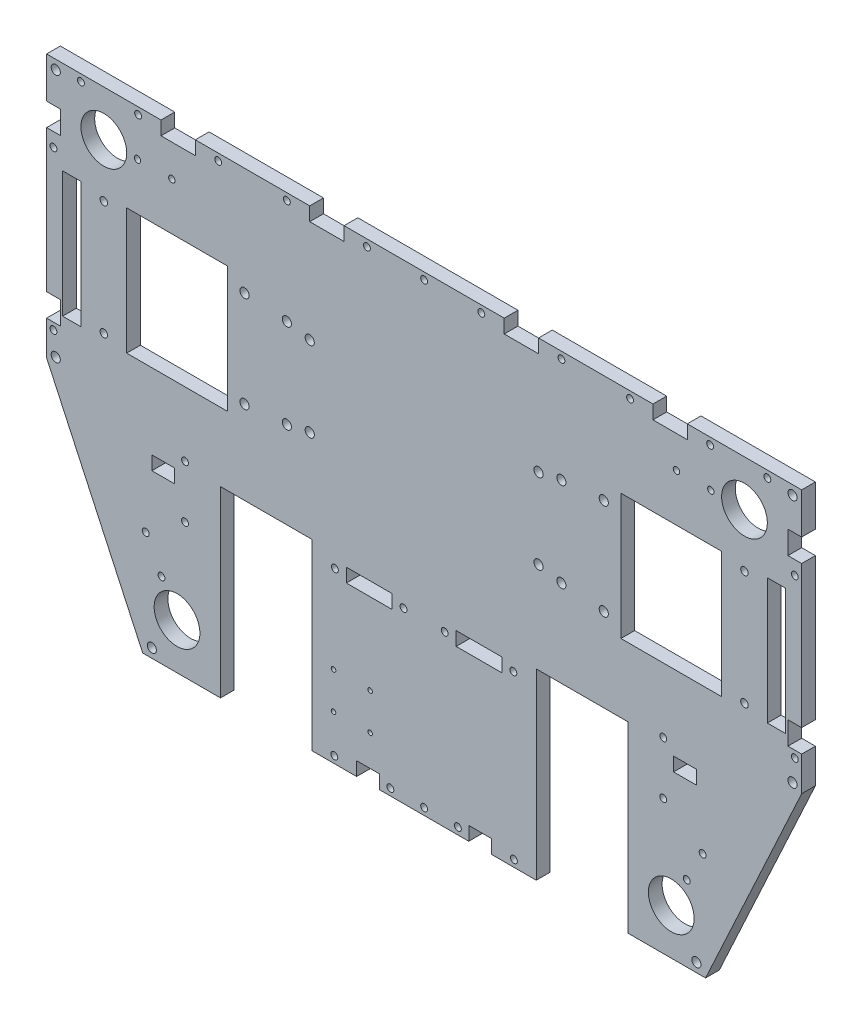
from build123d import *

# Parameters (mm, degrees)
ESQUISSE1_R             = 1
BOSS_EXTRU_1_DEPTH      = 6
ESQUISSE2_R             = 10
ESQUISSE2_R_2           = 2
ESQUISSE2_R_3           = 1.4
ESQUISSE2_R_4           = 1.5
ESQUISSE2_W             = 8
ESQUISSE2_H             = 55
ESQUISSE2_W_2           = 44
ESQUISSE2_W_3           = 40
ESQUISSE2_H_2           = 80
ENL_V_MAT_EXTRU_1_DEPTH = 6
ESQUISSE3_W             = 6
ESQUISSE3_H             = 10
ESQUISSE3_W_2           = 10
ESQUISSE3_H_2           = 6
ESQUISSE3_W_3           = 15
ENL_V_MAT_EXTRU_2_DEPTH = 6
ESQUISSE4_R             = 1.5
ENL_V_MAT_EXTRU_3_DEPTH = 6
ESQUISSE5_W             = 10
ESQUISSE5_H             = 6
ESQUISSE5_W_2           = 20
ENL_V_MAT_EXTRU_4_DEPTH = 6
ESQUISSE6_R             = 1.65
ESQUISSE6_R_2           = 1.5
ESQUISSE6_R_3           = 2
ENL_V_MAT_EXTRU_5_DEPTH = 6


with BuildPart() as part:
    # Esquisse1 → Boss.-Extru.1 (new body)
    with BuildSketch(Plane.XY):
        Polygon((-165, 96.73), (165, 96.73), (165, -18.27), (123, -109.022410436), (-123, -109.022410436), (-165, -18.27), align=None)
        with Locations((-23.6, -89.522410436)):
            Circle(ESQUISSE1_R, mode=Mode.SUBTRACT)
        with Locations((-23.6, -73.522410436)):
            Circle(ESQUISSE1_R, mode=Mode.SUBTRACT)
        with Locations((-39.6, -89.522410436)):
            Circle(ESQUISSE1_R, mode=Mode.SUBTRACT)
        with Locations((-39.6, -73.522410436)):
            Circle(ESQUISSE1_R, mode=Mode.SUBTRACT)
    extrude(amount=BOSS_EXTRU_1_DEPTH)

    # Esquisse2 → Enlèv. mat.-Extru.1 (cut)
    with BuildSketch(Plane.XY.offset(6)):
        with Locations((140, 76.73)):
            Circle(ESQUISSE2_R)
        with Locations((108, -89.022410436)):
            Circle(ESQUISSE2_R)
        with Locations((-140, 76.73)):
            Circle(ESQUISSE2_R)
        with Locations((-108, -89.022410436)):
            Circle(ESQUISSE2_R)
        with Locations((161, -16.022410436)):
            Circle(ESQUISSE2_R_2)
        with Locations((119, -105.022410436)):
            Circle(ESQUISSE2_R_2)
        with Locations((161, 92.73)):
            Circle(ESQUISSE2_R_2)
        with Locations((-161, 92.73)):
            Circle(ESQUISSE2_R_2)
        with Locations((-161, -16.022410436)):
            Circle(ESQUISSE2_R_2)
        with Locations((-119, -105.022410436)):
            Circle(ESQUISSE2_R_2)
        with Locations((125.27, 76.73)):
            Circle(ESQUISSE2_R_3)
        with Locations((110.27, 76.73)):
            Circle(ESQUISSE2_R_3)
        with Locations((114.7893454, -75.950391119)):
            Circle(ESQUISSE2_R_4)
        with Locations((121.703139086, -62.638762485)):
            Circle(ESQUISSE2_R_4)
        with Locations((-110.27, 76.73)):
            Circle(ESQUISSE2_R_3)
        with Locations((-125.27, 76.73)):
            Circle(ESQUISSE2_R_3)
        with Locations((-121.703139086, -62.638762485)):
            Circle(ESQUISSE2_R_4)
        with Locations((-114.7893454, -75.950391119)):
            Circle(ESQUISSE2_R_4)
        with Locations((-154, 28.477589564)):
            Rectangle(ESQUISSE2_W, ESQUISSE2_H)
        with Locations((-108, 28.477589564)):
            Rectangle(ESQUISSE2_W_2, ESQUISSE2_H)
        with Locations((108, 28.477589564)):
            Rectangle(ESQUISSE2_W_2, ESQUISSE2_H)
        with Locations((154, 28.477589564)):
            Rectangle(ESQUISSE2_W, ESQUISSE2_H)
        with Locations((69, -69.022410436)):
            Rectangle(ESQUISSE2_W_3, ESQUISSE2_H_2)
        with Locations((-69, -69.022410436)):
            Rectangle(ESQUISSE2_W_3, ESQUISSE2_H_2)
    extrude(amount=-ENL_V_MAT_EXTRU_1_DEPTH, mode=Mode.SUBTRACT)

    # Esquisse3 → Enlèv. mat.-Extru.2 (cut)
    with BuildSketch(Plane(origin=(0, 0, 0), x_dir=(-1, 0, 0), z_dir=(0, 0, -1))):
        with Locations((162, 1.73)):
            Rectangle(ESQUISSE3_W, ESQUISSE3_H)
        with Locations((162, 73.852589564)):
            Rectangle(ESQUISSE3_W, ESQUISSE3_H)
        with Locations((24.5, -106.022410436)):
            Rectangle(ESQUISSE3_W_2, ESQUISSE3_H_2)
        with Locations((-24.5, -106.022410436)):
            Rectangle(ESQUISSE3_W_2, ESQUISSE3_H_2)
        with Locations((-162, 73.852589564)):
            Rectangle(ESQUISSE3_W, ESQUISSE3_H)
        with Locations((-162, 1.73)):
            Rectangle(ESQUISSE3_W, ESQUISSE3_H)
        with Locations((107.5, 93.73)):
            Rectangle(ESQUISSE3_W_3, ESQUISSE3_H_2)
        with Locations((-42.5, 93.73)):
            Rectangle(ESQUISSE3_W_3, ESQUISSE3_H_2)
        with Locations((42.5, 93.73)):
            Rectangle(ESQUISSE3_W_3, ESQUISSE3_H_2)
        with Locations((-107.5, 93.73)):
            Rectangle(ESQUISSE3_W_3, ESQUISSE3_H_2)
    extrude(amount=-ENL_V_MAT_EXTRU_2_DEPTH, mode=Mode.SUBTRACT)

    # Esquisse4 → Enlèv. mat.-Extru.3 (cut)
    with BuildSketch(Plane(origin=(0, 0, 0), x_dir=(-1, 0, 0), z_dir=(0, 0, -1))):
        with Locations((162, -6.27)):
            Circle(ESQUISSE4_R)
        with Locations((0, -106.022410436)):
            Circle(ESQUISSE4_R)
        with Locations((162, 62.852589564)):
            Circle(ESQUISSE4_R)
        with Locations((0, 93.73)):
            Circle(ESQUISSE4_R)
        with Locations((-39.25, -106.022410436)):
            Circle(ESQUISSE4_R)
        with Locations((-14.75, -106.022410436)):
            Circle(ESQUISSE4_R)
        with Locations((14.75, -106.022410436)):
            Circle(ESQUISSE4_R)
        with Locations((39.25, -106.022410436)):
            Circle(ESQUISSE4_R)
        with Locations((150, 93.73)):
            Circle(ESQUISSE4_R)
        with Locations((125, 93.73)):
            Circle(ESQUISSE4_R)
        with Locations((90, 93.73)):
            Circle(ESQUISSE4_R)
        with Locations((-25, 93.73)):
            Circle(ESQUISSE4_R)
        with Locations((60, 93.73)):
            Circle(ESQUISSE4_R)
        with Locations((25, 93.73)):
            Circle(ESQUISSE4_R)
        with Locations((-60, 93.73)):
            Circle(ESQUISSE4_R)
        with Locations((-90, 93.73)):
            Circle(ESQUISSE4_R)
        with Locations((-125, 93.73)):
            Circle(ESQUISSE4_R)
        with Locations((-150, 93.73)):
            Circle(ESQUISSE4_R)
        with Locations((-162, 62.852589564)):
            Circle(ESQUISSE4_R)
        with Locations((-162, -6.27)):
            Circle(ESQUISSE4_R)
    extrude(amount=-ENL_V_MAT_EXTRU_3_DEPTH, mode=Mode.SUBTRACT)

    # Esquisse5 → Enlèv. mat.-Extru.4 (cut)
    with BuildSketch(Plane(origin=(0, 0, 0), x_dir=(-1, 0, 0), z_dir=(0, 0, -1))):
        with Locations((114, -35.022410436)):
            Rectangle(ESQUISSE5_W, ESQUISSE5_H)
        with Locations((24, -35.022410436)):
            Rectangle(ESQUISSE5_W_2, ESQUISSE5_H)
        with Locations((-24, -35.022410436)):
            Rectangle(ESQUISSE5_W_2, ESQUISSE5_H)
        with Locations((-114, -35.022410436)):
            Rectangle(ESQUISSE5_W, ESQUISSE5_H)
    extrude(amount=-ENL_V_MAT_EXTRU_4_DEPTH, mode=Mode.SUBTRACT)

    # Esquisse6 → Enlèv. mat.-Extru.5 (cut)
    with BuildSketch(Plane(origin=(0, 0, 0), x_dir=(-1, 0, 0), z_dir=(0, 0, -1))):
        with Locations((-140, 3.477589564)):
            Circle(ESQUISSE6_R)
        with Locations((-140, 53.477589564)):
            Circle(ESQUISSE6_R)
        with Locations((140, 53.477589564)):
            Circle(ESQUISSE6_R)
        with Locations((140, 3.477589564)):
            Circle(ESQUISSE6_R)
        with Locations((-39, -35.022410436)):
            Circle(ESQUISSE6_R_2)
        with Locations((9, -35.022410436)):
            Circle(ESQUISSE6_R_2)
        with Locations((39, -35.022410436)):
            Circle(ESQUISSE6_R_2)
        with Locations((-9, -35.022410436)):
            Circle(ESQUISSE6_R_2)
        with Locations((-78.5, 49.477589564)):
            Circle(ESQUISSE6_R_3)
        with Locations((-78.5, 7.477589564)):
            Circle(ESQUISSE6_R_3)
        with Locations((-60, 47.977589564)):
            Circle(ESQUISSE6_R_3)
        with Locations((-60, 8.977894939)):
            Circle(ESQUISSE6_R_3)
        with Locations((60, 8.977894939)):
            Circle(ESQUISSE6_R_3)
        with Locations((60, 47.977589564)):
            Circle(ESQUISSE6_R_3)
        with Locations((-50, 45.977589564)):
            Circle(ESQUISSE6_R_3)
        with Locations((50, 45.977589564)):
            Circle(ESQUISSE6_R_3)
        with Locations((50, 10.977589564)):
            Circle(ESQUISSE6_R_3)
        with Locations((-50, 10.977589564)):
            Circle(ESQUISSE6_R_3)
        with Locations((78.5, 7.477589564)):
            Circle(ESQUISSE6_R_3)
        with Locations((78.5, 49.477589564)):
            Circle(ESQUISSE6_R_3)
        with Locations((104.5, -27.222410436)):
            Circle(ESQUISSE6_R_2)
        with Locations((104.5, -50.222410436)):
            Circle(ESQUISSE6_R_2)
        with Locations((-104.5, -50.222410436)):
            Circle(ESQUISSE6_R_2)
        with Locations((-104.5, -27.222410436)):
            Circle(ESQUISSE6_R_2)
    extrude(amount=-ENL_V_MAT_EXTRU_5_DEPTH, mode=Mode.SUBTRACT)


solid = part.part
